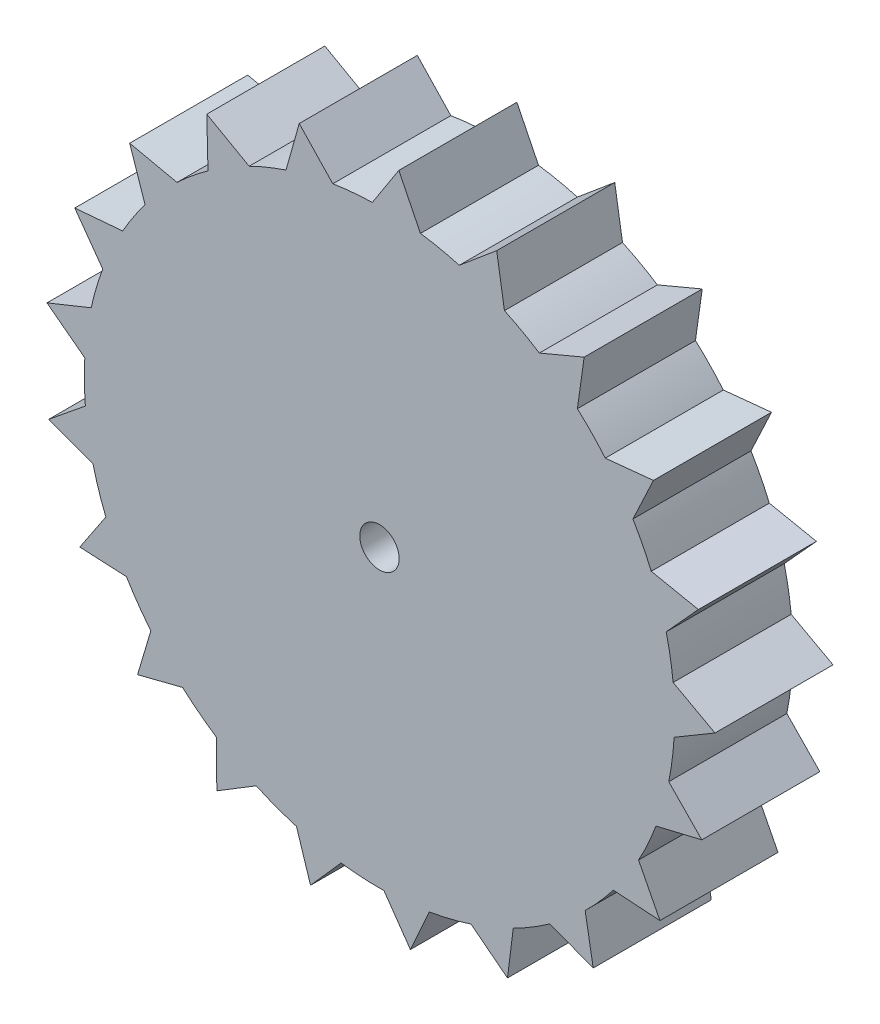
from build123d import *

# Parameters (mm, degrees)
BOSS_EXTRUDE1_DEPTH = 3
BOSS_EXTRUDE3_DEPTH = 3
CIRPATTERN1_COUNT   = 21
SKETCH7_R           = 2
BOSS_EXTRUDE4_DEPTH = 3
BOSS_EXTRUDE5_DEPTH = 3
CIRPATTERN2_COUNT   = 21
SKETCH9_R           = 0.5
CUT_EXTRUDE1_DEPTH  = 6


with BuildPart() as part:
    # Sketch3 → Boss-Extrude1 (new body)
    with BuildSketch(Plane(origin=(0, 0, -25.970633743), x_dir=(-1, 0, 0), z_dir=(0, 0, -1))):
        with BuildLine():
            ThreePointArc((-1.041352606, 75.627353819), (0.431341592, 60.712413978), (0.181550718, 75.6978023))
            Line((0.181550718, 75.6978023), (-1.041352606, 75.627353819))
        make_face()
    extrude(amount=BOSS_EXTRUDE1_DEPTH)

    # Sketch5 → Boss-Extrude3 (add)
    with BuildSketch(Plane.XY.offset(-25.970633743)):
        Polygon((-0.181550718, 75.6978023), (1.041352606, 75.627353819), (0.491951555, 76.73970416), align=None)
    boss_extrude3 = extrude(amount=-BOSS_EXTRUDE3_DEPTH)

    # CirPattern1: Boss-Extrude3 ×21 about axis
    cirpattern1_axis = Axis((0.001629139, 68.228279947, 0), (0, 0, 1))
    for i in range(1, CIRPATTERN1_COUNT):
        add(boss_extrude3.rotate(cirpattern1_axis, i * 360 / CIRPATTERN1_COUNT))

    # Sketch7 → Boss-Extrude4 (add)
    with BuildSketch(Plane(origin=(0, 0, -28.970633743), x_dir=(-1, 0, 0), z_dir=(0, 0, -1))):
        with Locations((0, 68.2)):
            Circle(SKETCH7_R)
    extrude(amount=BOSS_EXTRUDE4_DEPTH)

    # Sketch8 → Boss-Extrude5 (add)
    with BuildSketch(Plane(origin=(0, 0, -31.970633743), x_dir=(-1, 0, 0), z_dir=(0, 0, -1))):
        Polygon((0.4, 66.4), (-0.4, 66.4), (0, 65.6), align=None)
    boss_extrude5 = extrude(amount=-BOSS_EXTRUDE5_DEPTH)

    # CirPattern2: Boss-Extrude5 ×21 about axis
    cirpattern2_axis = Axis((0, 68.168195033, 0), (0, 0, 1))
    for i in range(1, CIRPATTERN2_COUNT):
        add(boss_extrude5.rotate(cirpattern2_axis, i * 360 / CIRPATTERN2_COUNT))

    # Sketch9 → Cut-Extrude1 (cut)
    with BuildSketch(Plane(origin=(0, 0, -31.970633743), x_dir=(-1, 0, 0), z_dir=(0, 0, -1))):
        with Locations((0, 68.2)):
            Circle(SKETCH9_R)
    extrude(amount=-CUT_EXTRUDE1_DEPTH, mode=Mode.SUBTRACT)


solid = part.part
